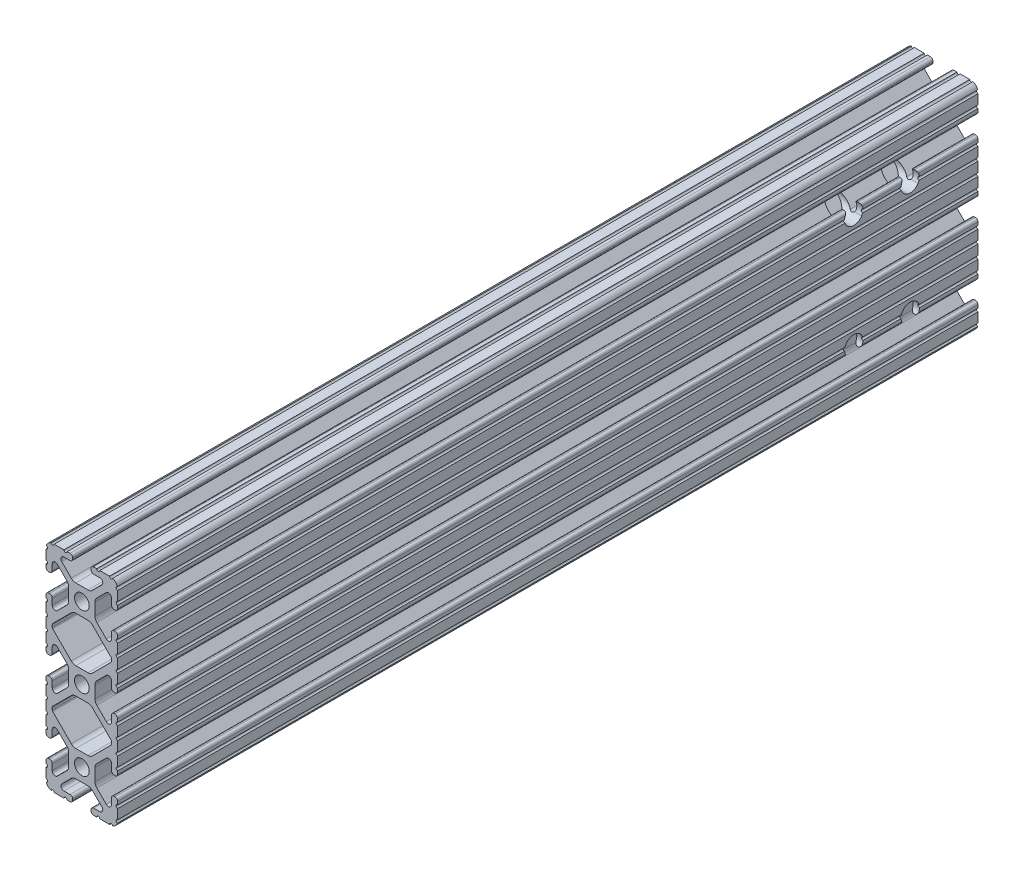
from build123d import *

# Parameters (mm, degrees)
BOSS_EXTRUDE1_DEPTH     = 152.4
SKETCH5_R               = 0.55245
CUT_EXTRUDE1_DEPTH      = 158.602855304
CUT_EXTRUDE1_DEPTH_BACK = 158.602855304
BOSS_EXTRUDE2_DEPTH     = 152.4
CUT_EXTRUDE2_DEPTH      = 158.602855304
CUT_EXTRUDE2_DEPTH_BACK = 158.602855304
SKETCH8_R               = 3.2639
CUT_EXTRUDE3_DEPTH      = 160.130543894


with BuildPart() as part:
    # Sketch4 → Boss-Extrude1 (new, symmetric)
    with BuildSketch(Plane.XY):
        with BuildLine():
            Line((4.190365, -38.1), (10.11729625, -38.1))
            ThreePointArc((10.11729625, -38.1), (11.943543585, -37.343543585), (12.7, -35.51729625))
            Line((12.7, -35.51729625), (12.7, -29.590365))
            ThreePointArc((12.7, -29.590365), (12.42492494, -28.92627506), (11.760835, -28.6512))
            Line((11.760835, -28.6512), (11.429365, -28.6512))
            ThreePointArc((11.429365, -28.6512), (10.76527506, -28.92627506), (10.4902, -29.590365))
            Line((10.4902, -29.590365), (10.4902, -31.748478019))
            ThreePointArc((10.4902, -31.748478019), (9.830707141, -32.735478831), (8.666460301, -32.503895736))
            Line((8.666460301, -32.503895736), (5.299899128, -29.137334563))
            ThreePointArc((5.299899128, -29.137334563), (4.817571085, -28.415479634), (4.6482, -27.56399369))
            Line((4.6482, -27.56399369), (4.6482, -25.4))
            Line((4.6482, -25.4), (2.6035, -25.4))
            ThreePointArc((2.6035, -25.4), (1.840952505, -27.240952505), (0, -28.0035))
            Line((0, -28.0035), (0, -30.0482))
            Line((0, -30.0482), (2.16399369, -30.0482))
            ThreePointArc((2.16399369, -30.0482), (3.015479634, -30.217571085), (3.737334563, -30.699899128))
            Line((3.737334563, -30.699899128), (7.103895736, -34.066460301))
            ThreePointArc((7.103895736, -34.066460301), (7.335478831, -35.230707141), (6.348478019, -35.8902))
            Line((6.348478019, -35.8902), (4.190365, -35.8902))
            ThreePointArc((4.190365, -35.8902), (3.52627506, -36.16527506), (3.2512, -36.829365))
            Line((3.2512, -36.829365), (3.2512, -37.160835))
            ThreePointArc((3.2512, -37.160835), (3.52627506, -37.82492494), (4.190365, -38.1))
        make_face()
    extrude(amount=BOSS_EXTRUDE1_DEPTH, both=True)

    # Sketch5 → Cut-Extrude1 (cut, two sides)
    with BuildSketch(Plane.XY) as cut_extrude1_sk:
        with Locations((10.356153152, -38.1)):
            Circle(SKETCH5_R)
        with Locations((5.796028019, -38.1)):
            Circle(SKETCH5_R)
        with Locations((12.7, -35.756153152)):
            Circle(SKETCH5_R)
        with Locations((12.7, -31.196028019)):
            Circle(SKETCH5_R)
    extrude(amount=CUT_EXTRUDE1_DEPTH, mode=Mode.SUBTRACT)
    extrude(cut_extrude1_sk.sketch, amount=-CUT_EXTRUDE1_DEPTH_BACK, mode=Mode.SUBTRACT)

    # Mirror1: part across plane


with BuildPart() as part_1:
    add(part.part)
    add(part.part.mirror(Plane(origin=(4.6482, -25.4, 152.4), x_dir=(0, 0, 1), z_dir=(0, -1, 0))))

    # Sketch6 → Boss-Extrude2 (add, symmetric)
    with BuildSketch(Plane.XY):
        with BuildLine():
            Line((12.7, -14.491396848), (12.7, -12.7))
            Line((12.7, -12.7), (9.803703152, -12.7))
            Line((9.803703152, -12.7), (9.803703152, -15.596296848))
            Line((9.803703152, -15.596296848), (12.7, -15.596296848))
            ThreePointArc((12.7, -15.596296848), (12.14755, -15.043846848), (12.7, -14.491396848))
        make_face()
    extrude(amount=BOSS_EXTRUDE2_DEPTH, both=True)

    # Sketch7 → Cut-Extrude2 (cut, two sides)
    with BuildSketch(Plane.XY) as cut_extrude2_sk:
        with BuildLine():
            Line((5.420615149, -18.416820286), (10.328391141, -13.509044294))
            ThreePointArc((10.328391141, -13.509044294), (10.448147248, -13.329816615), (10.4902, -13.118403152))
            Line((10.4902, -13.118403152), (10.4902, -12.7))
            Line((10.4902, -12.7), (0, -12.7))
            Line((0, -12.7), (5.420615149, -18.416820286))
        make_face()
    extrude(amount=CUT_EXTRUDE2_DEPTH, mode=Mode.SUBTRACT)
    extrude(cut_extrude2_sk.sketch, amount=-CUT_EXTRUDE2_DEPTH_BACK, mode=Mode.SUBTRACT)

    # Mirror2: part across plane


with BuildPart() as part_2:
    add(part_1.part)
    add(part_1.part.mirror(Plane(origin=(4.190365, -12.7, 152.4), x_dir=(0, 0, 1), z_dir=(0, -1, 0))))

    # SurfaceCut1
    split(bisect_by=Plane(origin=(0, 0, 0), x_dir=(1, 0, 0), z_dir=(0, 1, 0)), keep=Keep.BOTTOM)

    # Mirror3: part across plane


with BuildPart() as part_3:
    add(part_2.part)
    add(part_2.part.mirror(Plane(origin=(0, 0, 0), x_dir=(0, 0, 1), z_dir=(1, 0, 0))))

    # Mirror4: part across plane


with BuildPart() as part_4:
    add(part_3.part)
    add(part_3.part.mirror(Plane.ZX))

    # Sketch8 → Cut-Extrude3 (cut, through all)
    with BuildSketch(Plane.ZY.offset(12.7)):
        with Locations(Location((-108.4, 20, 0), (0, 0, 211.469383466))):
            Circle(SKETCH8_R)
        with Locations(Location((-128.4, 20, 0), (0, 0, 211.469383466))):
            Circle(SKETCH8_R)
        with Locations(Location((-128.4, -20, 0), (0, 0, 262.503958639))):
            Circle(SKETCH8_R)
        with Locations(Location((-108.4, -20, 0), (0, 0, 262.503958639))):
            Circle(SKETCH8_R)
    extrude(amount=-CUT_EXTRUDE3_DEPTH, mode=Mode.SUBTRACT)


solid = part_4.part
